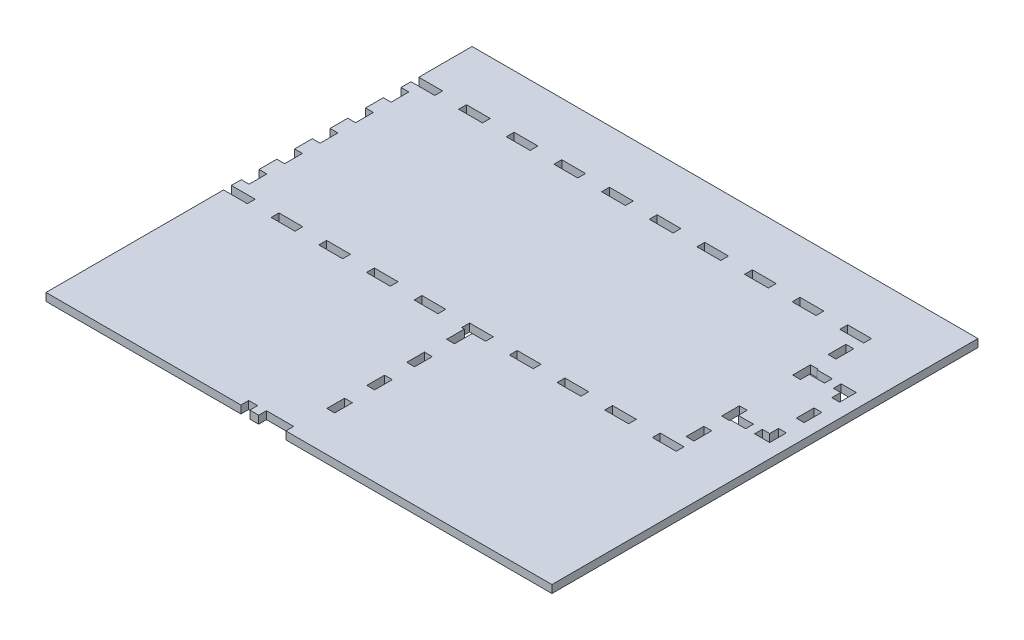
from build123d import *

# Parameters (mm, degrees)
SKETCH1_W              = 323.85
SKETCH1_H              = 139.7
BOSS_EXTRUDE1_DEPTH    = 5.588
SKETCH2_W              = 323.85
SKETCH2_H              = 139.7
SKETCH2_W_2            = 312.674
SKETCH2_H_2            = 128.524
BOSS_EXTRUDE2_DEPTH    = 298.45
SKETCH3_W              = 6.35
SKETCH3_H              = 16.933333333
SKETCH3_H_2            = 16.933333334
DOOR_SLOT_DEPTH        = 12.7
SKETCH4_W              = 6.35
SKETCH4_H              = 15.875
DOOR_GUIDE_HOLES_DEPTH = 5.588
LEVER_HOLES_W          = 9.652
LEVER_HOLES_H          = 6.35
LEVER_HOLES_W_2        = 6.35
CUT_EXTRUDE1_DEPTH     = 140.7
CUT_EXTRUDE2_REACH     = 325.85
SKETCH7_R              = 26.9875
CUT_EXTRUDE3_REACH     = 325.85
SKETCH8_R              = 3.175
SKETCH9_W              = 323.85
SKETCH9_H              = 298.45
CUT_EXTRUDE4_DEPTH     = 140.7
SKETCH10_W             = 11.456736842
SKETCH10_H             = 5.588
SKETCH10_W_2           = 5.588
SKETCH10_W_3           = 17.044736842
SKETCH10_W_4           = 17.044736843
SKETCH10_H_2           = 12.7
CUT_EXTRUDE6_DEPTH     = 6.588
SKETCH12_W             = 5.588
SKETCH12_H             = 12.7
BOSS_EXTRUDE3_DEPTH    = 5.588


with BuildPart() as part:
    # Sketch1 → Boss-Extrude1 (new body)
    with BuildSketch(Plane(origin=(0, 0, 0), x_dir=(1, 0, 0), z_dir=(0, 1, 0))):
        Rectangle(SKETCH1_W, SKETCH1_H)
    extrude(amount=BOSS_EXTRUDE1_DEPTH)

    # Sketch2 → Boss-Extrude2 (add)
    with BuildSketch(Plane(origin=(0, 5.588, 0), x_dir=(1, 0, 0), z_dir=(0, 1, 0))):
        Rectangle(SKETCH2_W, SKETCH2_H)
        Rectangle(SKETCH2_W_2, SKETCH2_H_2, mode=Mode.SUBTRACT)
    extrude(amount=BOSS_EXTRUDE2_DEPTH)

    # Sketch3 → Door Slot (cut)
    with BuildSketch(Plane.XY.offset(69.85)):
        with BuildLine():
            Line((-54.737, 282.448), (-54.737, 5.588))
            Line((-54.737, 5.588), (-48.133, 5.588))
            Line((-48.133, 5.588), (-48.133, 291.592))
            Line((-48.133, 291.592), (-67.691, 291.592))
            Line((-67.691, 291.592), (-67.691, 284.988))
            Line((-67.691, 284.988), (-57.277, 284.988))
            ThreePointArc((-57.277, 284.988), (-55.480948776, 284.244051224), (-54.737, 282.448))
        make_face()
        with Locations((-38.608, 80.433333334)):
            Rectangle(SKETCH3_W, SKETCH3_H)
        with Locations((-38.608, 50.8)):
            Rectangle(SKETCH3_W, SKETCH3_H_2)
        with Locations((-38.608, 21.166666667)):
            Rectangle(SKETCH3_W, SKETCH3_H)
    extrude(amount=-DOOR_SLOT_DEPTH, mode=Mode.SUBTRACT)

    # Sketch4 → Door Guide Holes (cut)
    with BuildSketch(Plane.XY.offset(-64.262)):
        with Locations((-70.866, 283.4005)):
            Rectangle(SKETCH4_W, SKETCH4_H)
        with Locations((-70.866, 254.8255)):
            Rectangle(SKETCH4_W, SKETCH4_H)
        with Locations((-70.866, 226.2505)):
            Rectangle(SKETCH4_W, SKETCH4_H)
        with Locations((-70.866, 197.6755)):
            Rectangle(SKETCH4_W, SKETCH4_H)
        with Locations((-70.866, 169.1005)):
            Rectangle(SKETCH4_W, SKETCH4_H)
        with Locations((-70.866, 140.5255)):
            Rectangle(SKETCH4_W, SKETCH4_H)
        with Locations((-70.866, 111.9505)):
            Rectangle(SKETCH4_W, SKETCH4_H)
        with Locations((-70.866, 83.3755)):
            Rectangle(SKETCH4_W, SKETCH4_H)
        with Locations((-70.866, 54.8005)):
            Rectangle(SKETCH4_W, SKETCH4_H)
        with Locations((-70.866, 26.2255)):
            Rectangle(SKETCH4_W, SKETCH4_H)
    door_guide_holes = extrude(amount=-DOOR_GUIDE_HOLES_DEPTH, mode=Mode.SUBTRACT)

    # Mirror1: Door Guide Holes across plane
    add(door_guide_holes.mirror(Plane.ZY.offset(57.912)), mode=Mode.SUBTRACT)

    # Lever Holes → Cut-Extrude1 (cut, through all)
    with BuildSketch(Plane.XY.offset(69.85)):
        with Locations((54.102, 28.575)):
            Rectangle(LEVER_HOLES_W, LEVER_HOLES_H)
        with Locations((39.3065, 15.875)):
            Rectangle(LEVER_HOLES_W_2, LEVER_HOLES_H)
        with Locations((68.8975, 15.875)):
            Rectangle(LEVER_HOLES_W_2, LEVER_HOLES_H)
    extrude(amount=-CUT_EXTRUDE1_DEPTH, mode=Mode.SUBTRACT)

    # Sketch7 → Cut-Extrude2 (cut, up to next)
    with BuildSketch(Plane(origin=(161.925, 0, 0), x_dir=(0, 0, -1), z_dir=(1, 0, 0)), mode=Mode.PRIVATE) as cut_extrude2_sk1:
        with Locations((0, 55.372)):
            Circle(SKETCH7_R)
    cut_extrude2_tool1 = extrude(cut_extrude2_sk1.sketch, amount=-CUT_EXTRUDE2_REACH, mode=Mode.PRIVATE) & part.part
    add(cut_extrude2_tool1.solids().sort_by_distance((161.925, 55.372, 0))[0], mode=Mode.SUBTRACT)
    # Sketch7 → Cut-Extrude2 (cut, up to next)
    with BuildSketch(Plane(origin=(161.925, 0, 0), x_dir=(0, 0, -1), z_dir=(1, 0, 0)), mode=Mode.PRIVATE) as cut_extrude2_sk2:
        with BuildLine():
            Line((-37.211, 89.408), (-37.211, 92.583))
            Line((-37.211, 92.583), (-34.036, 92.583))
            ThreePointArc((-34.036, 92.583), (-39.45606403, 94.82806403), (-37.211, 89.408))
        make_face()
    cut_extrude2_tool2 = extrude(cut_extrude2_sk2.sketch, amount=-CUT_EXTRUDE2_REACH, mode=Mode.PRIVATE) & part.part
    add(cut_extrude2_tool2.solids().sort_by_distance((161.925, 93.032171, 37.660171))[0], mode=Mode.SUBTRACT)
    # Sketch7 → Cut-Extrude2 (cut, up to next)
    with BuildSketch(Plane(origin=(161.925, 0, 0), x_dir=(0, 0, -1), z_dir=(1, 0, 0)), mode=Mode.PRIVATE) as cut_extrude2_sk3:
        with BuildLine():
            Line((-34.036, 92.583), (-37.211, 92.583))
            Line((-37.211, 92.583), (-37.211, 89.408))
            ThreePointArc((-37.211, 89.408), (-34.96593597, 90.33793597), (-34.036, 92.583))
        make_face()
    cut_extrude2_tool3 = extrude(cut_extrude2_sk3.sketch, amount=-CUT_EXTRUDE2_REACH, mode=Mode.PRIVATE) & part.part
    add(cut_extrude2_tool3.solids().sort_by_distance((161.925, 91.235488, 35.863488))[0], mode=Mode.SUBTRACT)
    # Sketch7 → Cut-Extrude2 (cut, up to next)
    with BuildSketch(Plane(origin=(161.925, 0, 0), x_dir=(0, 0, -1), z_dir=(1, 0, 0)), mode=Mode.PRIVATE) as cut_extrude2_sk4:
        with BuildLine():
            Line((-37.211, 89.408), (-37.211, 92.583))
            Line((-37.211, 92.583), (-34.036, 92.583))
            ThreePointArc((-34.036, 92.583), (-39.45606403, 94.82806403), (-37.211, 89.408))
        make_face()
    cut_extrude2_tool4 = extrude(cut_extrude2_sk4.sketch, amount=-CUT_EXTRUDE2_REACH, mode=Mode.PRIVATE) & part.part
    add(cut_extrude2_tool4.solids().sort_by_distance((161.925, 93.032171, 37.660171))[0], mode=Mode.SUBTRACT)
    # Sketch7 → Cut-Extrude2 (cut, up to next)
    with BuildSketch(Plane(origin=(161.925, 0, 0), x_dir=(0, 0, -1), z_dir=(1, 0, 0)), mode=Mode.PRIVATE) as cut_extrude2_sk5:
        with BuildLine():
            Line((-34.036, 92.583), (-37.211, 92.583))
            Line((-37.211, 92.583), (-37.211, 89.408))
            ThreePointArc((-37.211, 89.408), (-34.96593597, 90.33793597), (-34.036, 92.583))
        make_face()
    cut_extrude2_tool5 = extrude(cut_extrude2_sk5.sketch, amount=-CUT_EXTRUDE2_REACH, mode=Mode.PRIVATE) & part.part
    add(cut_extrude2_tool5.solids().sort_by_distance((161.925, 91.235488, 35.863488))[0], mode=Mode.SUBTRACT)
    # Sketch7 → Cut-Extrude2 (cut, up to next)
    with BuildSketch(Plane(origin=(161.925, 0, 0), x_dir=(0, 0, -1), z_dir=(1, 0, 0)), mode=Mode.PRIVATE) as cut_extrude2_sk6:
        with BuildLine():
            ThreePointArc((40.386, 92.583), (37.211, 95.758), (34.036, 92.583))
            Line((34.036, 92.583), (37.211, 92.583))
            Line((37.211, 92.583), (37.211, 89.408))
            ThreePointArc((37.211, 89.408), (39.45606403, 90.33793597), (40.386, 92.583))
        make_face()
    cut_extrude2_tool6 = extrude(cut_extrude2_sk6.sketch, amount=-CUT_EXTRUDE2_REACH, mode=Mode.PRIVATE) & part.part
    add(cut_extrude2_tool6.solids().sort_by_distance((161.925, 93.032171, -37.660171))[0], mode=Mode.SUBTRACT)
    # Sketch7 → Cut-Extrude2 (cut, up to next)
    with BuildSketch(Plane(origin=(161.925, 0, 0), x_dir=(0, 0, -1), z_dir=(1, 0, 0)), mode=Mode.PRIVATE) as cut_extrude2_sk7:
        with BuildLine():
            Line((37.211, 92.583), (34.036, 92.583))
            ThreePointArc((34.036, 92.583), (34.96593597, 90.33793597), (37.211, 89.408))
            Line((37.211, 89.408), (37.211, 92.583))
        make_face()
    cut_extrude2_tool7 = extrude(cut_extrude2_sk7.sketch, amount=-CUT_EXTRUDE2_REACH, mode=Mode.PRIVATE) & part.part
    add(cut_extrude2_tool7.solids().sort_by_distance((161.925, 91.235488, -35.863488))[0], mode=Mode.SUBTRACT)
    # Sketch7 → Cut-Extrude2 (cut, up to next)
    with BuildSketch(Plane(origin=(161.925, 0, 0), x_dir=(0, 0, -1), z_dir=(1, 0, 0)), mode=Mode.PRIVATE) as cut_extrude2_sk8:
        with BuildLine():
            ThreePointArc((40.386, 92.583), (37.211, 95.758), (34.036, 92.583))
            Line((34.036, 92.583), (37.211, 92.583))
            Line((37.211, 92.583), (37.211, 89.408))
            ThreePointArc((37.211, 89.408), (39.45606403, 90.33793597), (40.386, 92.583))
        make_face()
    cut_extrude2_tool8 = extrude(cut_extrude2_sk8.sketch, amount=-CUT_EXTRUDE2_REACH, mode=Mode.PRIVATE) & part.part
    add(cut_extrude2_tool8.solids().sort_by_distance((161.925, 93.032171, -37.660171))[0], mode=Mode.SUBTRACT)
    # Sketch7 → Cut-Extrude2 (cut, up to next)
    with BuildSketch(Plane(origin=(161.925, 0, 0), x_dir=(0, 0, -1), z_dir=(1, 0, 0)), mode=Mode.PRIVATE) as cut_extrude2_sk9:
        with BuildLine():
            Line((37.211, 92.583), (34.036, 92.583))
            ThreePointArc((34.036, 92.583), (34.96593597, 90.33793597), (37.211, 89.408))
            Line((37.211, 89.408), (37.211, 92.583))
        make_face()
    cut_extrude2_tool9 = extrude(cut_extrude2_sk9.sketch, amount=-CUT_EXTRUDE2_REACH, mode=Mode.PRIVATE) & part.part
    add(cut_extrude2_tool9.solids().sort_by_distance((161.925, 91.235488, -35.863488))[0], mode=Mode.SUBTRACT)
    # Sketch7 → Cut-Extrude2 (cut, up to next)
    with BuildSketch(Plane(origin=(161.925, 0, 0), x_dir=(0, 0, -1), z_dir=(1, 0, 0)), mode=Mode.PRIVATE) as cut_extrude2_sk10:
        with BuildLine():
            ThreePointArc((-34.036, 18.161), (-34.96593597, 20.40606403), (-37.211, 21.336))
            Line((-37.211, 21.336), (-37.211, 18.161))
            Line((-37.211, 18.161), (-34.036, 18.161))
        make_face()
    cut_extrude2_tool10 = extrude(cut_extrude2_sk10.sketch, amount=-CUT_EXTRUDE2_REACH, mode=Mode.PRIVATE) & part.part
    add(cut_extrude2_tool10.solids().sort_by_distance((161.925, 19.508512, 35.863488))[0], mode=Mode.SUBTRACT)
    # Sketch7 → Cut-Extrude2 (cut, up to next)
    with BuildSketch(Plane(origin=(161.925, 0, 0), x_dir=(0, 0, -1), z_dir=(1, 0, 0)), mode=Mode.PRIVATE) as cut_extrude2_sk11:
        with BuildLine():
            Line((-37.211, 18.161), (-37.211, 21.336))
            ThreePointArc((-37.211, 21.336), (-39.45606403, 15.91593597), (-34.036, 18.161))
            Line((-34.036, 18.161), (-37.211, 18.161))
        make_face()
    cut_extrude2_tool11 = extrude(cut_extrude2_sk11.sketch, amount=-CUT_EXTRUDE2_REACH, mode=Mode.PRIVATE) & part.part
    add(cut_extrude2_tool11.solids().sort_by_distance((161.925, 17.711829, 37.660171))[0], mode=Mode.SUBTRACT)
    # Sketch7 → Cut-Extrude2 (cut, up to next)
    with BuildSketch(Plane(origin=(161.925, 0, 0), x_dir=(0, 0, -1), z_dir=(1, 0, 0)), mode=Mode.PRIVATE) as cut_extrude2_sk12:
        with BuildLine():
            ThreePointArc((-34.036, 18.161), (-34.96593597, 20.40606403), (-37.211, 21.336))
            Line((-37.211, 21.336), (-37.211, 18.161))
            Line((-37.211, 18.161), (-34.036, 18.161))
        make_face()
    cut_extrude2_tool12 = extrude(cut_extrude2_sk12.sketch, amount=-CUT_EXTRUDE2_REACH, mode=Mode.PRIVATE) & part.part
    add(cut_extrude2_tool12.solids().sort_by_distance((161.925, 19.508512, 35.863488))[0], mode=Mode.SUBTRACT)
    # Sketch7 → Cut-Extrude2 (cut, up to next)
    with BuildSketch(Plane(origin=(161.925, 0, 0), x_dir=(0, 0, -1), z_dir=(1, 0, 0)), mode=Mode.PRIVATE) as cut_extrude2_sk13:
        with BuildLine():
            Line((-37.211, 18.161), (-37.211, 21.336))
            ThreePointArc((-37.211, 21.336), (-39.45606403, 15.91593597), (-34.036, 18.161))
            Line((-34.036, 18.161), (-37.211, 18.161))
        make_face()
    cut_extrude2_tool13 = extrude(cut_extrude2_sk13.sketch, amount=-CUT_EXTRUDE2_REACH, mode=Mode.PRIVATE) & part.part
    add(cut_extrude2_tool13.solids().sort_by_distance((161.925, 17.711829, 37.660171))[0], mode=Mode.SUBTRACT)
    # Sketch7 → Cut-Extrude2 (cut, up to next)
    with BuildSketch(Plane(origin=(161.925, 0, 0), x_dir=(0, 0, -1), z_dir=(1, 0, 0)), mode=Mode.PRIVATE) as cut_extrude2_sk14:
        with BuildLine():
            ThreePointArc((40.386, 18.161), (39.45606403, 20.40606403), (37.211, 21.336))
            Line((37.211, 21.336), (37.211, 18.161))
            Line((37.211, 18.161), (34.036, 18.161))
            ThreePointArc((34.036, 18.161), (37.211, 14.986), (40.386, 18.161))
        make_face()
    cut_extrude2_tool14 = extrude(cut_extrude2_sk14.sketch, amount=-CUT_EXTRUDE2_REACH, mode=Mode.PRIVATE) & part.part
    add(cut_extrude2_tool14.solids().sort_by_distance((161.925, 17.711829, -37.660171))[0], mode=Mode.SUBTRACT)
    # Sketch7 → Cut-Extrude2 (cut, up to next)
    with BuildSketch(Plane(origin=(161.925, 0, 0), x_dir=(0, 0, -1), z_dir=(1, 0, 0)), mode=Mode.PRIVATE) as cut_extrude2_sk15:
        with BuildLine():
            Line((37.211, 18.161), (37.211, 21.336))
            ThreePointArc((37.211, 21.336), (34.96593597, 20.40606403), (34.036, 18.161))
            Line((34.036, 18.161), (37.211, 18.161))
        make_face()
    cut_extrude2_tool15 = extrude(cut_extrude2_sk15.sketch, amount=-CUT_EXTRUDE2_REACH, mode=Mode.PRIVATE) & part.part
    add(cut_extrude2_tool15.solids().sort_by_distance((161.925, 19.508512, -35.863488))[0], mode=Mode.SUBTRACT)
    # Sketch7 → Cut-Extrude2 (cut, up to next)
    with BuildSketch(Plane(origin=(161.925, 0, 0), x_dir=(0, 0, -1), z_dir=(1, 0, 0)), mode=Mode.PRIVATE) as cut_extrude2_sk16:
        with BuildLine():
            ThreePointArc((40.386, 18.161), (39.45606403, 20.40606403), (37.211, 21.336))
            Line((37.211, 21.336), (37.211, 18.161))
            Line((37.211, 18.161), (34.036, 18.161))
            ThreePointArc((34.036, 18.161), (37.211, 14.986), (40.386, 18.161))
        make_face()
    cut_extrude2_tool16 = extrude(cut_extrude2_sk16.sketch, amount=-CUT_EXTRUDE2_REACH, mode=Mode.PRIVATE) & part.part
    add(cut_extrude2_tool16.solids().sort_by_distance((161.925, 17.711829, -37.660171))[0], mode=Mode.SUBTRACT)
    # Sketch7 → Cut-Extrude2 (cut, up to next)
    with BuildSketch(Plane(origin=(161.925, 0, 0), x_dir=(0, 0, -1), z_dir=(1, 0, 0)), mode=Mode.PRIVATE) as cut_extrude2_sk17:
        with BuildLine():
            Line((37.211, 18.161), (37.211, 21.336))
            ThreePointArc((37.211, 21.336), (34.96593597, 20.40606403), (34.036, 18.161))
            Line((34.036, 18.161), (37.211, 18.161))
        make_face()
    cut_extrude2_tool17 = extrude(cut_extrude2_sk17.sketch, amount=-CUT_EXTRUDE2_REACH, mode=Mode.PRIVATE) & part.part
    add(cut_extrude2_tool17.solids().sort_by_distance((161.925, 19.508512, -35.863488))[0], mode=Mode.SUBTRACT)

    # Sketch8 → Cut-Extrude3 (cut, up to next)
    with BuildSketch(Plane.ZY.offset(161.925), mode=Mode.PRIVATE) as cut_extrude3_sk1:
        with Locations((0, 19.05)):
            Circle(SKETCH8_R)
    cut_extrude3_tool1 = extrude(cut_extrude3_sk1.sketch, amount=-CUT_EXTRUDE3_REACH, mode=Mode.PRIVATE) & part.part
    add(cut_extrude3_tool1.solids().sort_by_distance((-161.925, 19.05, 0))[0], mode=Mode.SUBTRACT)

    # Sketch9 → Cut-Extrude4 (cut, through all)
    with BuildSketch(Plane(origin=(0, 0, -69.85), x_dir=(-1, 0, 0), z_dir=(0, 0, -1))):
        with Locations((0, 154.813)):
            Rectangle(SKETCH9_W, SKETCH9_H)
    extrude(amount=-CUT_EXTRUDE4_DEPTH, mode=Mode.SUBTRACT)

    # Sketch10 → Cut-Extrude6 (cut, through all)
    with BuildSketch(Plane.XZ):
        with Locations((-150.608631579, 67.056)):
            Rectangle(SKETCH10_W, SKETCH10_H)
        with Locations((-159.131, 67.056)):
            Rectangle(SKETCH10_W_2, SKETCH10_H)
        with Locations((-119.313157895, 67.056)):
            Rectangle(SKETCH10_W_3, SKETCH10_H)
        with Locations((-85.223684211, 67.056)):
            Rectangle(SKETCH10_W_4, SKETCH10_H)
        with Locations((-51.134210526, 67.056)):
            Rectangle(SKETCH10_W_3, SKETCH10_H)
        with Locations((-17.044736842, 67.056)):
            Rectangle(SKETCH10_W_3, SKETCH10_H)
        with Locations((17.044736842, 67.056)):
            Rectangle(SKETCH10_W_3, SKETCH10_H)
        with Locations((51.134210526, 67.056)):
            Rectangle(SKETCH10_W_3, SKETCH10_H)
        with Locations((85.223684211, 67.056)):
            Rectangle(SKETCH10_W_4, SKETCH10_H)
        with Locations((119.313157895, 67.056)):
            Rectangle(SKETCH10_W_3, SKETCH10_H)
        with Locations((150.608631579, 67.056)):
            Rectangle(SKETCH10_W, SKETCH10_H)
        with Locations((159.131, 67.056)):
            Rectangle(SKETCH10_W_2, SKETCH10_H)
        with Locations((159.131, 50.8)):
            Rectangle(SKETCH10_W_2, SKETCH10_H_2)
        with Locations((159.131, 25.4)):
            Rectangle(SKETCH10_W_2, SKETCH10_H_2)
        with Locations((159.131, -25.4)):
            Rectangle(SKETCH10_W_2, SKETCH10_H_2)
        with Locations((159.131, -50.8)):
            Rectangle(SKETCH10_W_2, SKETCH10_H_2)
        with Locations((159.131, -67.056)):
            Rectangle(SKETCH10_W_2, SKETCH10_H)
        with Locations((150.608631579, -67.056)):
            Rectangle(SKETCH10_W, SKETCH10_H)
        with Locations((119.313157895, -67.056)):
            Rectangle(SKETCH10_W_3, SKETCH10_H)
        with Locations((85.223684211, -67.056)):
            Rectangle(SKETCH10_W_4, SKETCH10_H)
        with Locations((51.134210526, -67.056)):
            Rectangle(SKETCH10_W_3, SKETCH10_H)
        with Locations((17.044736842, -67.056)):
            Rectangle(SKETCH10_W_3, SKETCH10_H)
        with Locations((-17.044736842, -67.056)):
            Rectangle(SKETCH10_W_3, SKETCH10_H)
        with Locations((-51.134210526, -67.056)):
            Rectangle(SKETCH10_W_3, SKETCH10_H)
        with Locations((-85.223684211, -67.056)):
            Rectangle(SKETCH10_W_4, SKETCH10_H)
        with Locations((-119.313157895, -67.056)):
            Rectangle(SKETCH10_W_3, SKETCH10_H)
        with Locations((-159.131, -67.056)):
            Rectangle(SKETCH10_W_2, SKETCH10_H)
        with Locations((-150.608631579, -67.056)):
            Rectangle(SKETCH10_W, SKETCH10_H)
        with Locations((-159.131, -50.8)):
            Rectangle(SKETCH10_W_2, SKETCH10_H_2)
        with Locations((-159.131, -25.4)):
            Rectangle(SKETCH10_W_2, SKETCH10_H_2)
        with Locations((-159.131, 0)):
            Rectangle(SKETCH10_W_2, SKETCH10_H_2)
        with Locations((-159.131, 25.4)):
            Rectangle(SKETCH10_W_2, SKETCH10_H_2)
        with Locations((-159.131, 50.8)):
            Rectangle(SKETCH10_W_2, SKETCH10_H_2)
    extrude(amount=-CUT_EXTRUDE6_DEPTH, mode=Mode.SUBTRACT)

    # Sketch12 → Boss-Extrude3 (add)
    with BuildSketch(Plane(origin=(0, 0, 0), x_dir=(-1, 0, 0), z_dir=(0, -1, 0))):
        Polygon((22.479, -196.85), (161.925, -196.85), (161.925, -69.85), (-10.414, -69.85), (-10.414, -82.55), (-16.002, -82.55), (-16.002, -69.85), (-161.925, -69.85), (-161.925, -30.988), (-172.75, -30.988), (-172.75, -25.4), (-161.925, -25.4), (-161.925, 25.4), (-172.75, 25.4), (-172.75, 30.988), (-161.925, 30.988), (-161.925, 69.85), (161.925, 69.85), (161.925, 107.95), (-200.025, 107.95), (-200.025, -196.85), (-9.652, -196.85), (-9.652, -191.262), (9.779, -191.262), (9.779, -196.85), (16.129, -196.85), (16.129, -191.262), (22.479, -191.262), align=None)
        with Locations((-13.208, -161.925)):
            Rectangle(SKETCH12_W, SKETCH12_H, mode=Mode.SUBTRACT)
        with Locations((-13.208, -133.35)):
            Rectangle(SKETCH12_W, SKETCH12_H, mode=Mode.SUBTRACT)
        with Locations((-13.208, -104.775)):
            Rectangle(SKETCH12_W, SKETCH12_H, mode=Mode.SUBTRACT)
        Polygon((-179.1, 30.988), (-179.1, 25.4), (-184.337, 25.4), (-184.337, 19.05), (-189.925, 19.05), (-189.925, 30.988), align=None, mode=Mode.SUBTRACT)
        Polygon((-179.1, -25.4), (-179.1, -30.988), (-189.925, -30.988), (-189.925, -19.05), (-184.337, -19.05), (-184.337, -25.4), align=None, mode=Mode.SUBTRACT)
        with Locations((-187.131, 0)):
            Rectangle(SKETCH12_W, SKETCH12_H, mode=Mode.SUBTRACT)
    extrude(amount=-BOSS_EXTRUDE3_DEPTH)


solid = part.part
